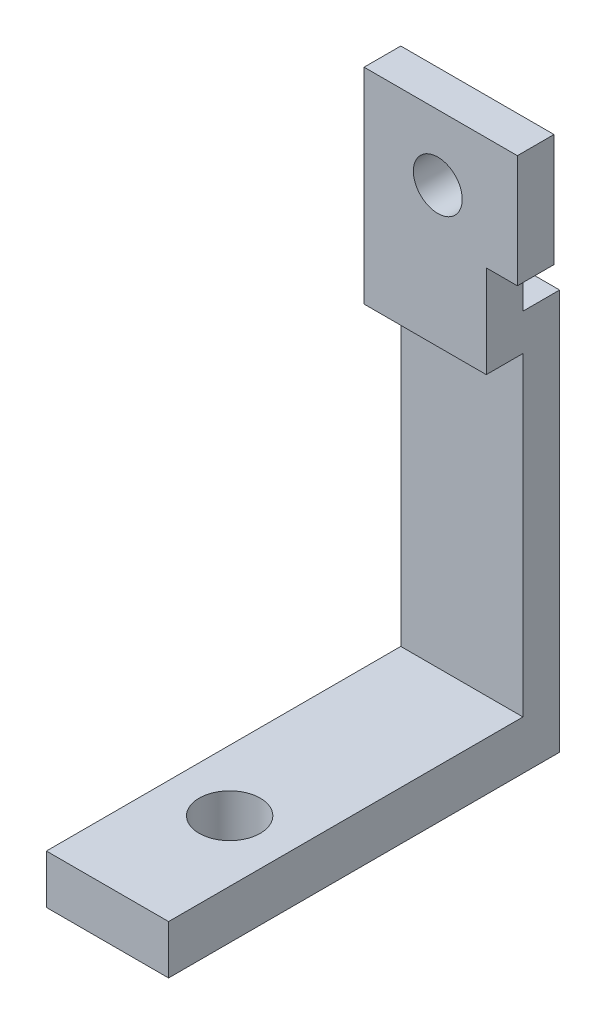
from build123d import *

# Parameters (mm, degrees)
SKETCH1_W           = 10
SKETCH1_H           = 32
BOSS_EXTRUDE1_DEPTH = 4
SKETCH2_R           = 2.5
CUT_EXTRUDE1_DEPTH  = 4
SKETCH3_W           = 10
SKETCH3_H           = 3
BOSS_EXTRUDE2_DEPTH = 28.76
SKETCH4_W           = 2.542985542
SKETCH4_H           = 9.222544282
BOSS_EXTRUDE3_DEPTH = 3
SKETCH5_R           = 2
CUT_EXTRUDE2_DEPTH  = 13


with BuildPart() as part:
    # Sketch1 → Boss-Extrude1 (new body)
    with BuildSketch(Plane(origin=(0, 0, 0), x_dir=(1, 0, 0), z_dir=(0, 1, 0))):
        with Locations((5, 16)):
            Rectangle(SKETCH1_W, SKETCH1_H)
    extrude(amount=BOSS_EXTRUDE1_DEPTH)

    # Sketch2 → Cut-Extrude1 (cut)
    with BuildSketch(Plane(origin=(0, 4, 0), x_dir=(1, 0, 0), z_dir=(0, 1, 0))):
        with Locations((5, 10)):
            Circle(SKETCH2_R)
    extrude(amount=-CUT_EXTRUDE1_DEPTH, mode=Mode.SUBTRACT)

    # Sketch3 → Boss-Extrude2 (add)
    with BuildSketch(Plane(origin=(0, 4, 0), x_dir=(1, 0, 0), z_dir=(0, 1, 0))):
        with Locations((5, 30.5)):
            Rectangle(SKETCH3_W, SKETCH3_H)
    extrude(amount=BOSS_EXTRUDE2_DEPTH)

    # Sketch4 → Boss-Extrude3 (add)
    with BuildSketch(Plane.XY.offset(-29)):
        Polygon((10, 37.329817811), (10, 46.552362093), (0, 46.552362093), (0, 29.76), (10, 29.76), align=None)
        with Locations((11.271492771, 41.941089952)):
            Rectangle(SKETCH4_W, SKETCH4_H)
    extrude(amount=BOSS_EXTRUDE3_DEPTH)

    # Sketch5 → Cut-Extrude2 (cut)
    with BuildSketch(Plane.XY.offset(-26)):
        with Locations((6.030433289, 41.199403662)):
            Circle(SKETCH5_R)
    extrude(amount=-CUT_EXTRUDE2_DEPTH, mode=Mode.SUBTRACT)


solid = part.part
